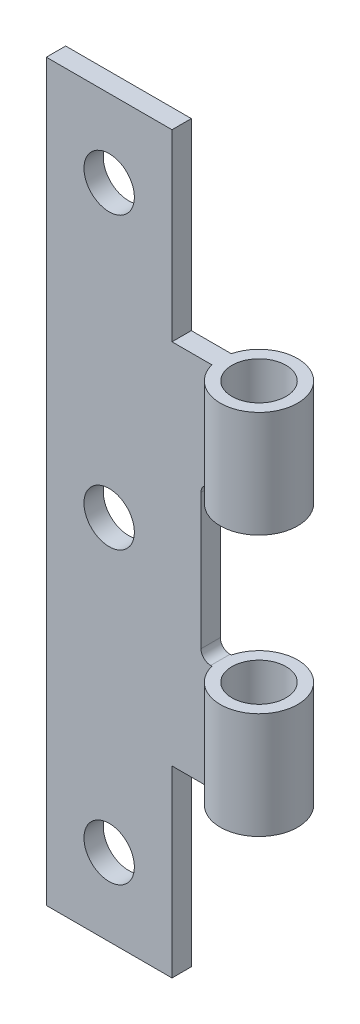
from build123d import *

# Parameters (mm, degrees)
SKETCH1_R           = 1.4
BOSS_EXTRUDE1_DEPTH = 5.5
SKETCH2_R           = 1.4
BOSS_EXTRUDE2_DEPTH = 5.5
SKETCH3_W           = 8
SKETCH3_H           = 1
BOSS_EXTRUDE3_DEPTH = 13.5
SKETCH4_W           = 6.5
SKETCH4_H           = 1
BOSS_EXTRUDE4_DEPTH = 9.5
SKETCH5_W           = 6.5
SKETCH5_H           = 1
BOSS_EXTRUDE5_DEPTH = 9.5
FILLET1_R           = 0.5
CUT_EXTRUDE1_REACH  = 4.5
SKETCH6_R           = 1.303868107


with BuildPart() as part:
    # Sketch1 → Boss-Extrude1 (new body)
    with BuildSketch(Plane(origin=(0, 0, 0), x_dir=(1, 0, 0), z_dir=(0, 1, 0))):
        with BuildLine():
            Line((-1.936491673, 0.5), (-10.5, 0.5))
            Line((-10.5, 0.5), (-10.5, -0.5))
            Line((-10.5, -0.5), (-1.936491673, -0.5))
            ThreePointArc((-1.936491673, -0.5), (2, 0), (-1.936491673, 0.5))
        make_face()
        Circle(SKETCH1_R, mode=Mode.SUBTRACT)
    extrude(amount=BOSS_EXTRUDE1_DEPTH)



with BuildPart() as body_2:
    # Sketch2 → Boss-Extrude2 (new body)
    with BuildSketch(Plane(origin=(0, 13.5, 0), x_dir=(1, 0, 0), z_dir=(0, 1, 0))):
        with BuildLine():
            Line((-1.936491673, 0.5), (-10.5, 0.5))
            Line((-10.5, 0.5), (-10.5, -0.5))
            Line((-10.5, -0.5), (-1.936491673, -0.5))
            ThreePointArc((-1.936491673, -0.5), (2, 0), (-1.936491673, 0.5))
        make_face()
        Circle(SKETCH2_R, mode=Mode.SUBTRACT)
    extrude(amount=BOSS_EXTRUDE2_DEPTH)


with BuildPart() as part_1:
    add(part.part)

    add(body_2.part)  # Boss-Extrude3 merges body 2
    # Sketch3 → Boss-Extrude3 (add)
    with BuildSketch(Plane(origin=(0, 5.5, 0), x_dir=(1, 0, 0), z_dir=(0, 1, 0))):
        with Locations((-6.5, 0)):
            Rectangle(SKETCH3_W, SKETCH3_H)
    extrude(amount=BOSS_EXTRUDE3_DEPTH)

    # Sketch4 → Boss-Extrude4 (add)
    with BuildSketch(Plane(origin=(0, 19, 0), x_dir=(1, 0, 0), z_dir=(0, 1, 0))):
        with Locations((-7.25, 0)):
            Rectangle(SKETCH4_W, SKETCH4_H)
    extrude(amount=BOSS_EXTRUDE4_DEPTH)

    # Sketch5 → Boss-Extrude5 (add)
    with BuildSketch(Plane.XZ):
        with Locations((-7.25, 0)):
            Rectangle(SKETCH5_W, SKETCH5_H)
    extrude(amount=BOSS_EXTRUDE5_DEPTH)

    # Fillet1
    fillet1_edges = [part_1.edges().sort_by_distance(p)[0] for p in [
        (-2.5, 13.5, 0),
        (-2.5, 5.5, 0),
    ]]
    fillet(fillet1_edges, radius=FILLET1_R)

    # Sketch6 → Cut-Extrude1 (cut, up to next)
    with BuildSketch(Plane.XY.offset(0.5), mode=Mode.PRIVATE) as cut_extrude1_sk1:
        with Locations((-7.25, -5.5)):
            Circle(SKETCH6_R)
    cut_extrude1_tool1 = extrude(cut_extrude1_sk1.sketch, amount=-CUT_EXTRUDE1_REACH, mode=Mode.PRIVATE) & part_1.part
    add(cut_extrude1_tool1.solids().sort_by_distance((-7.25, -5.5, 0.5))[0], mode=Mode.SUBTRACT)
    # Sketch6 → Cut-Extrude1 (cut, up to next)
    with BuildSketch(Plane.XY.offset(0.5), mode=Mode.PRIVATE) as cut_extrude1_sk2:
        with Locations((-7.25, 9.5)):
            Circle(SKETCH6_R)
    cut_extrude1_tool2 = extrude(cut_extrude1_sk2.sketch, amount=-CUT_EXTRUDE1_REACH, mode=Mode.PRIVATE) & part_1.part
    add(cut_extrude1_tool2.solids().sort_by_distance((-7.25, 9.5, 0.5))[0], mode=Mode.SUBTRACT)
    # Sketch6 → Cut-Extrude1 (cut, up to next)
    with BuildSketch(Plane.XY.offset(0.5), mode=Mode.PRIVATE) as cut_extrude1_sk3:
        with Locations((-7.25, 24.5)):
            Circle(SKETCH6_R)
    cut_extrude1_tool3 = extrude(cut_extrude1_sk3.sketch, amount=-CUT_EXTRUDE1_REACH, mode=Mode.PRIVATE) & part_1.part
    add(cut_extrude1_tool3.solids().sort_by_distance((-7.25, 24.5, 0.5))[0], mode=Mode.SUBTRACT)


solid = part_1.part
